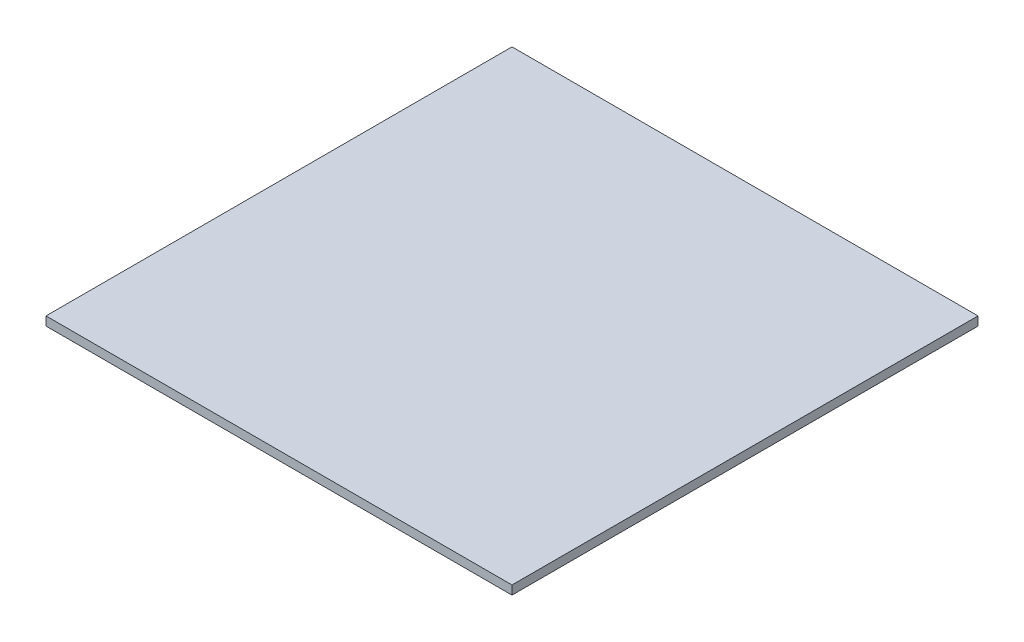
from build123d import *

# Parameters (mm, degrees)
SKETCH1_W           = 108.585
SKETCH1_H           = 108.585
MAIN_PLATE_DEPTH    = 1.5875
SKETCH2_W           = 133.985
SKETCH2_H           = 133.985
BOSS_EXTRUDE2_DEPTH = 2.54


with BuildPart() as part:
    # Sketch1 → Main Plate (new body)
    with BuildSketch(Plane(origin=(0, 0, 0), x_dir=(1, 0, 0), z_dir=(0, 1, 0))):
        with Locations((-54.2925, 54.2925)):
            Rectangle(SKETCH1_W, SKETCH1_H)
    extrude(amount=MAIN_PLATE_DEPTH)

    # Sketch2 → Boss-Extrude2 (add)
    with BuildSketch(Plane(origin=(0, 1.5875, 0), x_dir=(1, 0, 0), z_dir=(0, 1, 0))):
        with Locations((-54.2925, 54.2925)):
            Rectangle(SKETCH2_W, SKETCH2_H)
    extrude(amount=BOSS_EXTRUDE2_DEPTH)


solid = part.part
